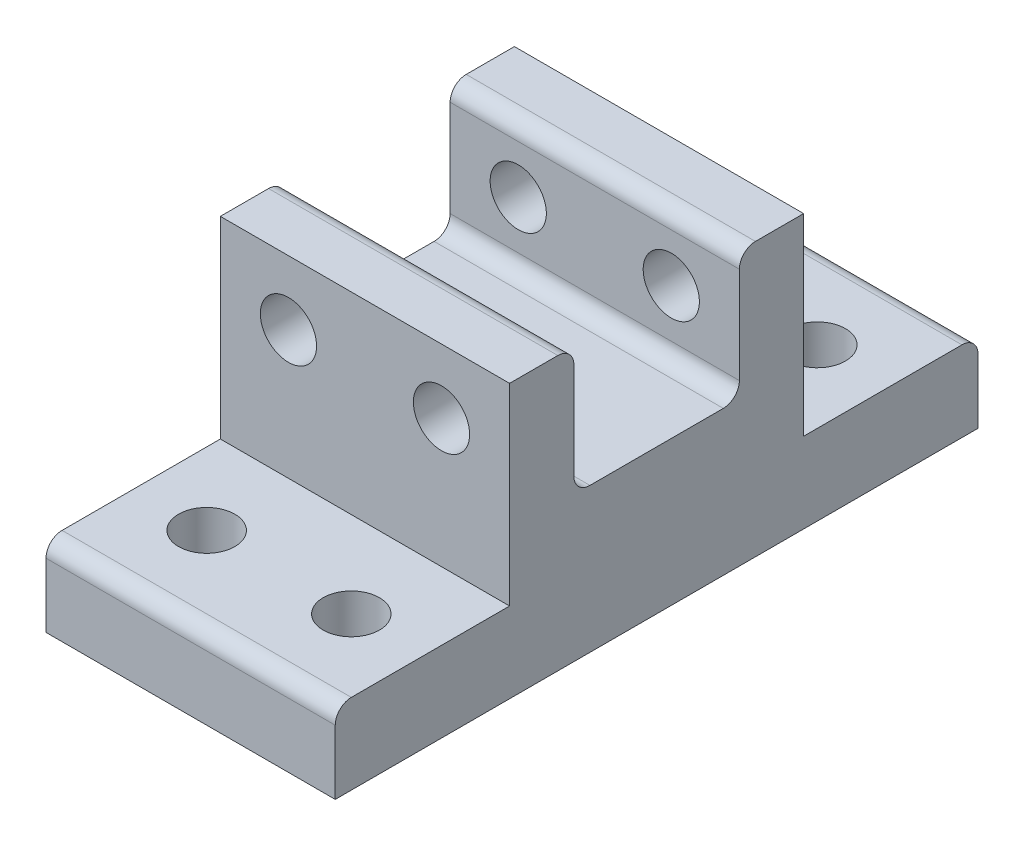
from build123d import *

# Parameters (mm, degrees)
SKETCH1_W               = 18
SKETCH1_H               = 18.3
BOSS_EXTRUDE1_DEPTH     = 3
SKETCH2_W               = 18
SKETCH2_H               = 4
BOSS_EXTRUDE3_DEPTH     = 8
SKETCH3_R               = 1.75
CUT_EXTRUDE2_DEPTH      = 20
CUT_EXTRUDE2_DEPTH_BACK = 13
FILLET1_R               = 1
FILLET2_R               = 1
FILLET3_R               = 1
SKETCH4_W               = 18
SKETCH4_H               = 18.3
BOSS_EXTRUDE4_DEPTH     = 1
SKETCH5_W               = 18
SKETCH5_H               = 40
BOSS_EXTRUDE5_DEPTH     = 5
SKETCH6_R               = 1.75
CUT_EXTRUDE4_DEPTH      = 5
FILLET4_R               = 1
FILLET5_R               = 1


with BuildPart() as part:
    # Sketch1 → Boss-Extrude1 (new body)
    with BuildSketch(Plane(origin=(0, 0, 0), x_dir=(1, 0, 0), z_dir=(0, 1, 0))):
        Rectangle(SKETCH1_W, SKETCH1_H)
    extrude(amount=BOSS_EXTRUDE1_DEPTH)

    # Sketch2 → Boss-Extrude3 (add)
    with BuildSketch(Plane(origin=(0, 3, 0), x_dir=(1, 0, 0), z_dir=(0, 1, 0))):
        with Locations((0, -7.15)):
            Rectangle(SKETCH2_W, SKETCH2_H)
        with Locations((0, 7.15)):
            Rectangle(SKETCH2_W, SKETCH2_H)
    extrude(amount=BOSS_EXTRUDE3_DEPTH)

    # Sketch3 → Cut-Extrude2 (cut, two sides)
    with BuildSketch(Plane(origin=(0, 0, 5.15), x_dir=(-1, 0, 0), z_dir=(0, 0, -1))) as cut_extrude2_sk:
        with Locations((-4.762, 7)):
            Circle(SKETCH3_R)
        with Locations((4.762, 7)):
            Circle(SKETCH3_R)
    extrude(amount=CUT_EXTRUDE2_DEPTH, mode=Mode.SUBTRACT)
    extrude(cut_extrude2_sk.sketch, amount=-CUT_EXTRUDE2_DEPTH_BACK, mode=Mode.SUBTRACT)

    # Fillet1
    fillet1_edges = [part.edges().sort_by_distance(p)[0] for p in [
        (0, 3, 5.15),
    ]]
    fillet(fillet1_edges, radius=FILLET1_R)

    # Fillet2
    fillet2_edges = [part.edges().sort_by_distance(p)[0] for p in [
        (0, 3, -5.15),
    ]]
    fillet(fillet2_edges, radius=FILLET2_R)

    # Fillet3
    fillet3_edges = [part.edges().sort_by_distance(p)[0] for p in [
        (0, 11, 5.15),
        (0, 11, -5.15),
    ]]
    fillet(fillet3_edges, radius=FILLET3_R)

    # Sketch4 → Boss-Extrude4 (add)
    with BuildSketch(Plane.XZ):
        Rectangle(SKETCH4_W, SKETCH4_H)
    extrude(amount=BOSS_EXTRUDE4_DEPTH)

    # Sketch5 → Boss-Extrude5 (add)
    with BuildSketch(Plane(origin=(0, -1, 0), x_dir=(-1, 0, 0), z_dir=(0, -1, 0))):
        Rectangle(SKETCH5_W, SKETCH5_H)
    extrude(amount=BOSS_EXTRUDE5_DEPTH)

    # Sketch6 → Cut-Extrude4 (cut)
    with BuildSketch(Plane.XZ.offset(6)):
        with Locations((4.5, 14.5)):
            Circle(SKETCH6_R)
        with Locations((-4.5, 14.5)):
            Circle(SKETCH6_R)
        with Locations((-4.5, -14.5)):
            Circle(SKETCH6_R)
        with Locations((4.5, -14.5)):
            Circle(SKETCH6_R)
    extrude(amount=-CUT_EXTRUDE4_DEPTH, mode=Mode.SUBTRACT)

    # Fillet4
    fillet4_edges = [part.edges().sort_by_distance(p)[0] for p in [
        (0, -1, -20),
    ]]
    fillet(fillet4_edges, radius=FILLET4_R)

    # Fillet5
    fillet5_edges = [part.edges().sort_by_distance(p)[0] for p in [
        (0, -1, 20),
    ]]
    fillet(fillet5_edges, radius=FILLET5_R)


solid = part.part
